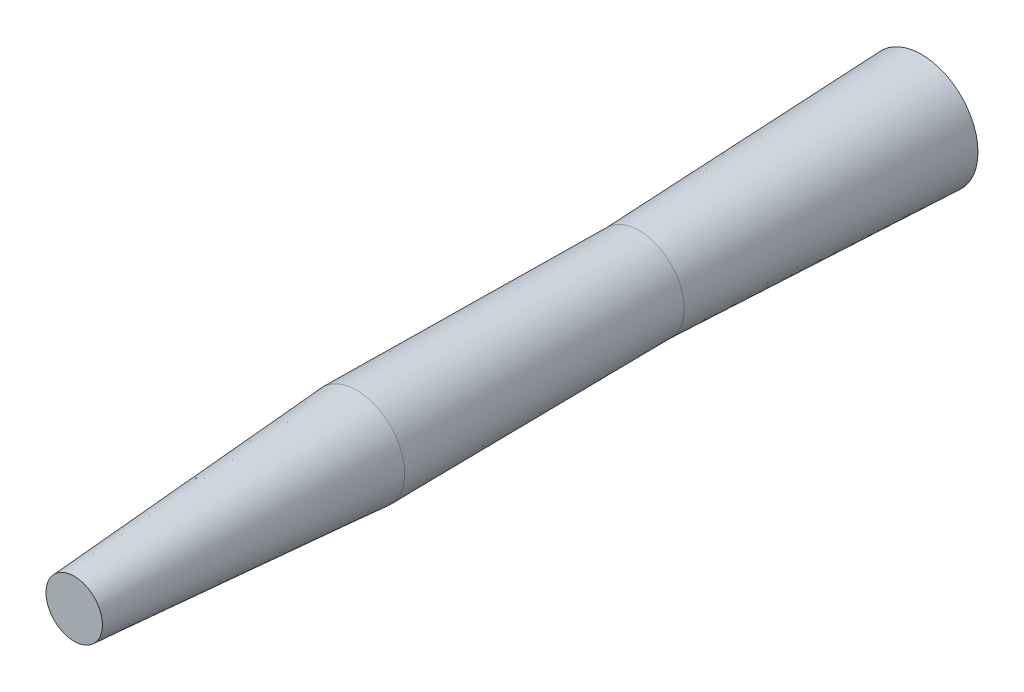
from build123d import *

# Parameters (mm, degrees)
SKETCH1_R = 20
SKETCH2_R = 16
SKETCH3_R = 17
SKETCH4_R = 10


with BuildPart() as part:
    # Sketch1 → Loft1 section 0
    with BuildSketch(Plane.XY):
        Circle(SKETCH1_R)
    # Sketch2 → Loft1 section 1
    with BuildSketch(Plane.XY.offset(100)):
        Circle(SKETCH2_R)
    loft()

    # Sketch3 → section 1 of loft4
    with BuildSketch(Plane.XY.offset(200), mode=Mode.PRIVATE) as loft4_s1:
        Circle(SKETCH3_R)
    # loft up to a face of the part (loft4)
    loft([Face(Wire([part.edges().sort_by_distance((-10.952753695, 11.663498039, 100))[0]])), loft4_s1.sketch])

    # Sketch4 → section 1 of loft5
    with BuildSketch(Plane.XY.offset(300), mode=Mode.PRIVATE) as loft5_s1:
        Circle(SKETCH4_R)
    # loft up to a face of the part (loft5)
    loft([Face(Wire([part.edges().sort_by_distance((-11.637300801, 12.392466666, 200))[0]])), loft5_s1.sketch])


solid = part.part
